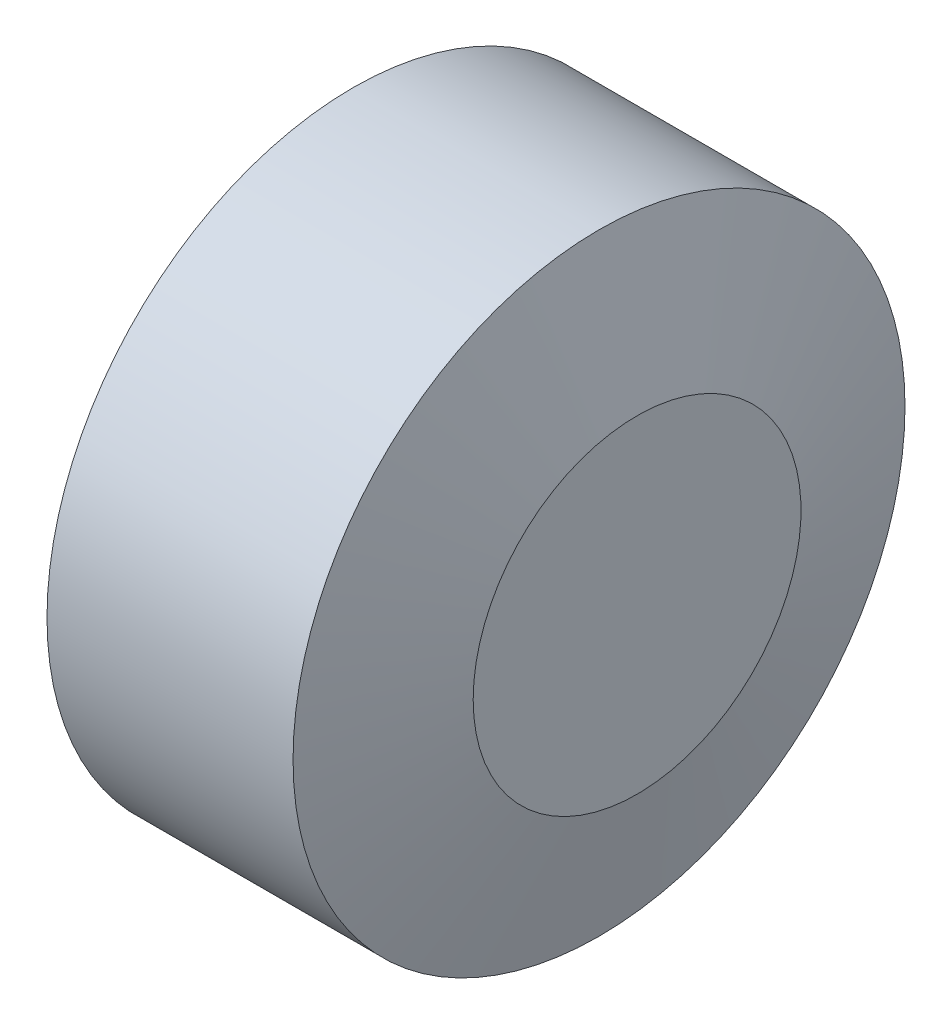
from build123d import *


with BuildPart() as part:
    # Skizze1 → Rotation1 (revolve)
    with BuildSketch(Plane.XY, mode=Mode.PRIVATE) as rotation1_sk:
        Polygon((0, 0), (0, -14), (11.258330249, -14), (13, -7.5), (13, 0), align=None)
    revolve(rotation1_sk.sketch.rotate(Axis((0, 0, 0), (1, 0, 0)), 270), axis=Axis((0, 0, 0), (1, 0, 0)))  # turned: the seam where the file's is


solid = part.part
